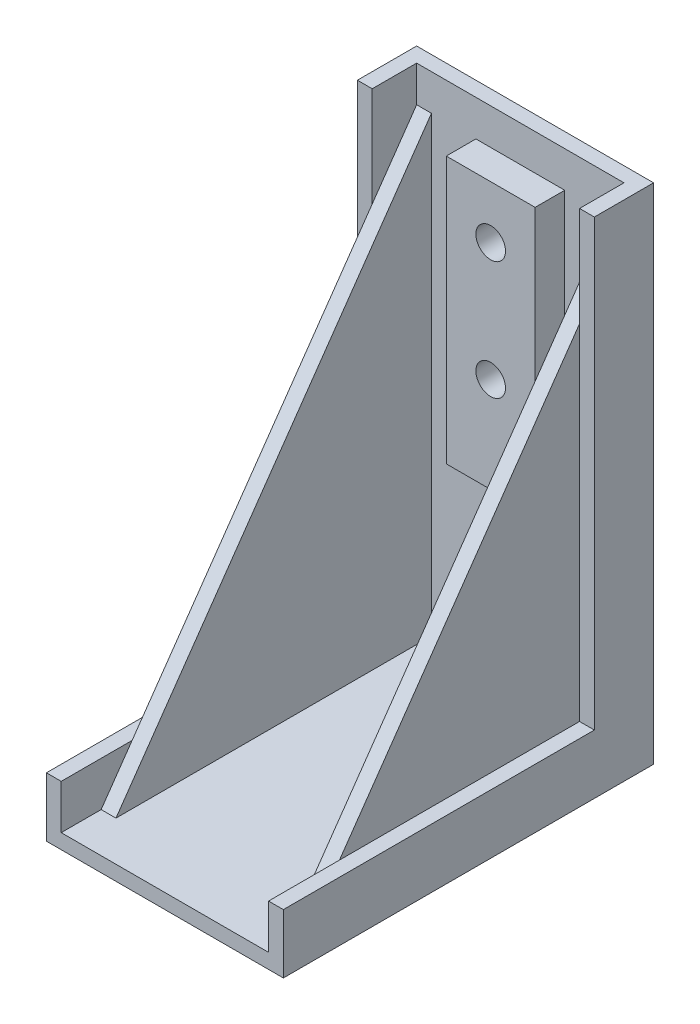
from build123d import *

# Parameters (mm, degrees)
BOSS_EXTRUDE1_DEPTH = 10
SHELL1_T            = -1.25
RIB1_REACH          = 57.985
SKETCH4_WALL_W      = 164.251441786
SKETCH4_WALL_H      = 1.25
SKETCH5_W           = 7.5
SKETCH5_H           = 22.5
BOSS_EXTRUDE2_DEPTH = 2.5
SKETCH6_R           = 1.25
CUT_EXTRUDE1_DEPTH  = 52.599418601


with BuildPart() as part:
    # Sketch1 → Boss-Extrude1 (new, symmetric)
    with BuildSketch(Plane(origin=(0, 0, 0), x_dir=(0, 0, -1), z_dir=(1, 0, 0))):
        Polygon((0, 0), (31.25, 0), (31.25, 42.5), (26.25, 42.5), (26.25, 5), (0, 5), align=None)
    extrude(amount=BOSS_EXTRUDE1_DEPTH, both=True)

    # Shell1
    shell1_openings = [part.faces().sort_by_distance(p)[0] for p in [
        (0, 5, -13.125),
        (0, 23.75, -26.25),
        (0, 42.5, -28.75),
        (0, 2.5, 0),
    ]]
    offset(amount=SHELL1_T, openings=shell1_openings, kind=Kind.INTERSECTION)

    # Sketch4 wall → Rib1 (add, up to next)
    with BuildSketch(Plane(origin=(-8.75, 20.625, -16.875), x_dir=(0, 0.82039816677, -0.571792661688), z_dir=(0, 0.571792661688, 0.82039816677)), mode=Mode.PRIVATE) as rib1_sk1:
        with Locations((0, -0.625)):
            Rectangle(SKETCH4_WALL_W, SKETCH4_WALL_H)
    rib1_tool1 = extrude(rib1_sk1.sketch, amount=-RIB1_REACH, mode=Mode.PRIVATE) - part.part
    rib1 = rib1_tool1.solids().sort_by_distance((-8.75, 20.625, -16.875))[0]
    add(rib1)

    # Mirror1: Rib1 across plane
    add(rib1.mirror(Plane(origin=(0, 0, 0), x_dir=(0, 0, 1), z_dir=(1, 0, 0))))

    # Sketch5 → Boss-Extrude2 (add)
    with BuildSketch(Plane.XY.offset(-30)):
        with Locations((0, 28.206521739)):
            Rectangle(SKETCH5_W, SKETCH5_H)
    extrude(amount=BOSS_EXTRUDE2_DEPTH)

    # Sketch6 → Cut-Extrude1 (cut, through all)
    with BuildSketch(Plane.XY.offset(-27.5)):
        with Locations((0, 35)):
            Circle(SKETCH6_R)
        with Locations((0, 25)):
            Circle(SKETCH6_R)
    extrude(amount=-CUT_EXTRUDE1_DEPTH, mode=Mode.SUBTRACT)


solid = part.part
